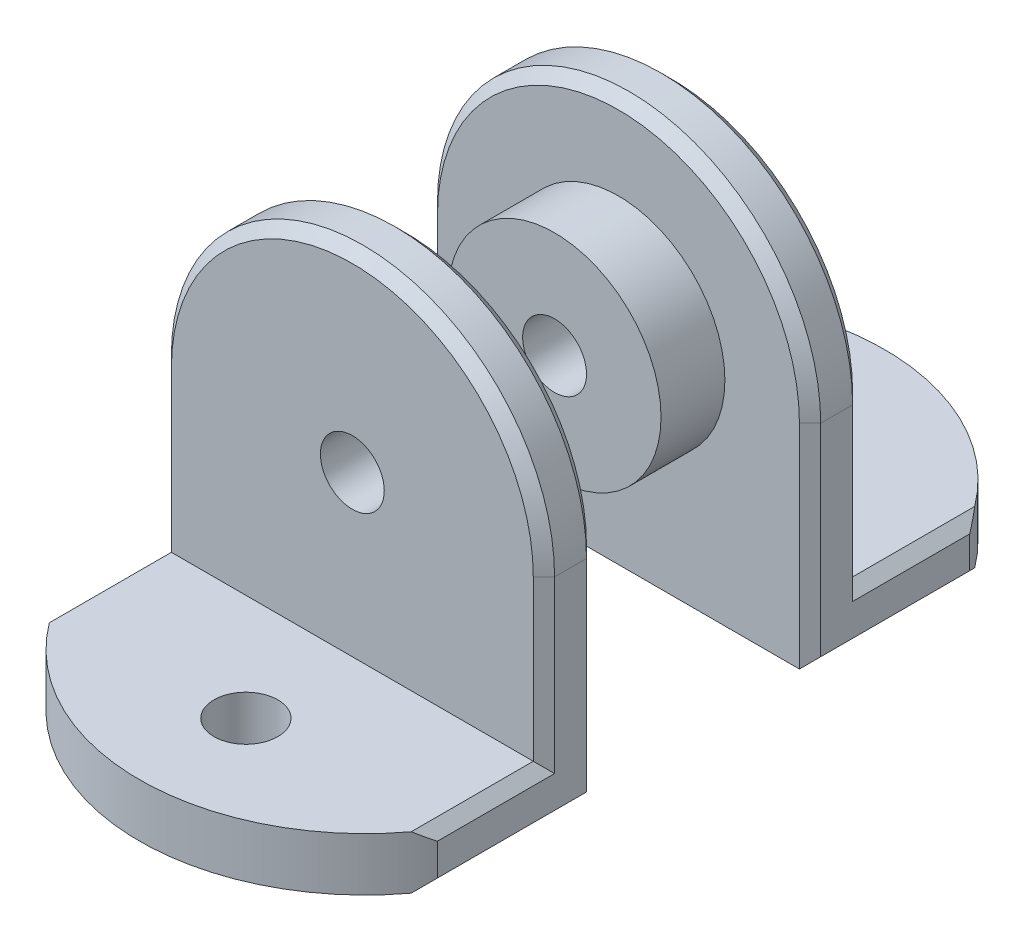
from build123d import *

# Parameters (mm, degrees)
SKETCH1_R           = 3
BOSS_EXTRUDE1_DEPTH = 5
BOSS_EXTRUDE3_DEPTH = 5
SKETCH4_R           = 10
SKETCH4_R_2         = 3
BOSS_EXTRUDE4_DEPTH = 6
CHAMFER1_SIZE       = 1
CHAMFER2_SIZE       = 1


with BuildPart() as part:
    # Sketch1 → Boss-Extrude1 (new body)
    with BuildSketch(Plane.XY):
        with BuildLine():
            Line((-18, -20), (18, -20))
            Line((18, -20), (18, 0))
            ThreePointArc((18, 0), (0, 18), (-18, 0))
            Line((-18, 0), (-18, -20))
        make_face()
        Circle(SKETCH1_R, mode=Mode.SUBTRACT)
    extrude(amount=BOSS_EXTRUDE1_DEPTH)

    # Sketch3 → Boss-Extrude3 (add)
    with BuildSketch(Plane.XZ.offset(20)):
        with BuildLine():
            Line((-18, 15), (-18, 0))
            Line((-18, 0), (18, 0))
            Line((18, 0), (18, 15))
            Line((18, 15), (3, 15))
            ThreePointArc((3, 15), (0, 12), (-3, 15))
            Line((-3, 15), (-18, 15))
        make_face()
        with BuildLine():
            ThreePointArc((18, 15), (0, 25), (-18, 15))
            Line((-18, 15), (-3, 15))
            ThreePointArc((-3, 15), (0, 18), (3, 15))
            Line((3, 15), (18, 15))
        make_face()
    extrude(amount=-BOSS_EXTRUDE3_DEPTH)


with BuildPart() as body_2:
    # Mirror2: mirrored copy
    add(part.part.mirror(Plane.XY))


with BuildPart() as part_1:
    # Body-Move/Copy2: moved
    add(part.part.moved(Location((0, 0, 10))))

    # Chamfer1
    chamfer1_edges = [part_1.edges().sort_by_distance(p)[0] for p in [
        (0, 18, 15),
        (18, -7.5, 15),
        (18, -15, 20),
        (-18, -15, 20),
        (-18, -7.5, 15),
        (0, 18, 10),
        (18, -10, 10),
        (-18, -10, 10),
        (18, -20, 17.5),
        (-18, -20, 17.5),
    ]]
    chamfer(chamfer1_edges, length=CHAMFER1_SIZE)


with BuildPart() as body_2_1:
    # Body-Move/Copy3: moved
    add(body_2.part.moved(Location((0, 0, -10))))

    # Sketch4 → Boss-Extrude4 (add)
    with BuildSketch(Plane.XY.offset(-10)):
        Circle(SKETCH4_R)
        Circle(SKETCH4_R_2, mode=Mode.SUBTRACT)
    extrude(amount=BOSS_EXTRUDE4_DEPTH)

    # Chamfer2
    chamfer2_edges = [body_2_1.edges().sort_by_distance(p)[0] for p in [
        (0, 18, -15),
        (18, -7.5, -15),
        (18, -15, -20),
        (-18, -15, -20),
        (-18, -7.5, -15),
        (0, 18, -10),
        (18, -10, -10),
        (-18, -10, -10),
        (18, -20, -17.5),
        (-18, -20, -17.5),
    ]]
    chamfer(chamfer2_edges, length=CHAMFER2_SIZE)


solid = Compound([part_1.part, body_2_1.part])
